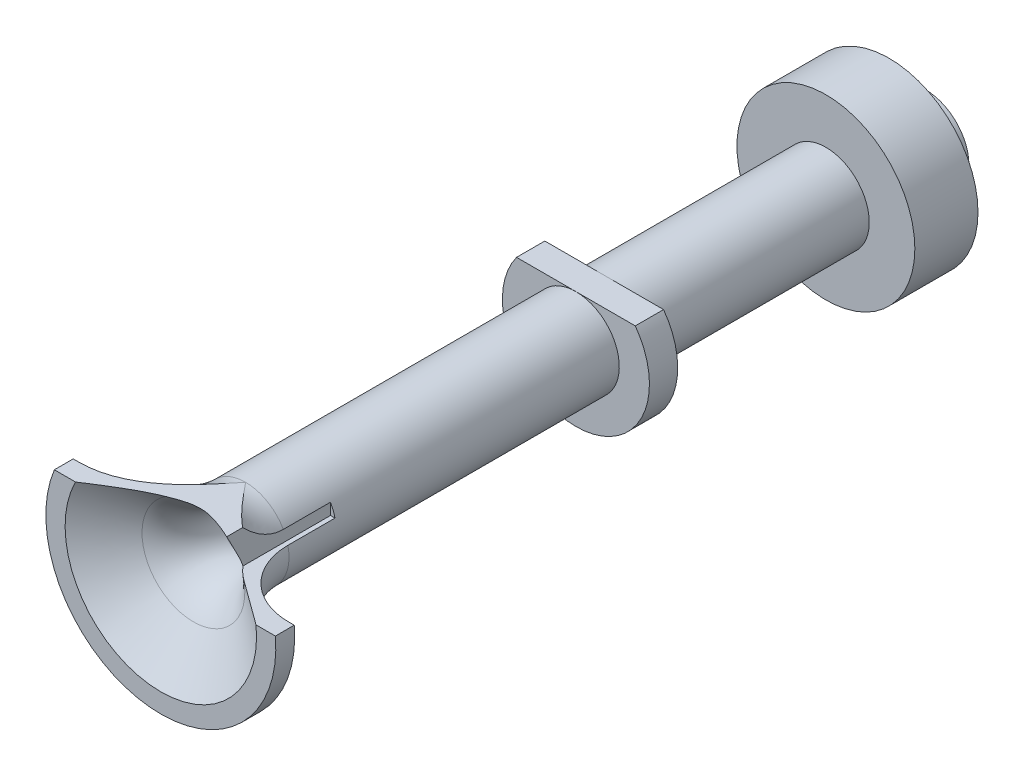
from build123d import *

# Parameters (mm, degrees)
CUT_EXTRUDE1_DEPTH      = 7
SKETCH3_W               = 26.933594661
SKETCH3_H               = 5.726695828
CUT_EXTRUDE2_DEPTH      = 7.1
CUT_EXTRUDE2_DEPTH_BACK = 7.1


with BuildPart() as part:
    # Sketch1 → Revolve1 (revolve)
    with BuildSketch(Plane(origin=(0, 0, 0), x_dir=(0, 0, -1), z_dir=(1, 0, 0))):
        with BuildLine():
            Line((19.186178752, 5.078211692), (19.186178752, 6.1))
            Line((19.186178752, 6.1), (20.186178752, 6.1))
            Line((20.186178752, 6.1), (20.186178752, 5.8))
            ThreePointArc((20.186178752, 5.8), (21.211305018, 3.325126266), (23.686178752, 2.3))
            Line((23.686178752, 2.3), (41.207308429, 2.3))
            Line((41.207308429, 2.3), (41.207308429, 3.9))
            Line((41.207308429, 3.9), (42.707308429, 3.9))
            Line((42.707308429, 3.9), (42.707308429, 2.3))
            Line((42.707308429, 2.3), (54.469152884, 2.3))
            Line((54.469152884, 2.3), (54.469152884, 4.719165839))
            Line((54.469152884, 4.719165839), (57.819152884, 4.719165839))
            Line((57.819152884, 4.719165839), (57.819152884, 2.3))
            Line((57.819152884, 2.3), (59.757795324, 2.3))
            Line((59.757795324, 2.3), (59.757795324, 1.3))
            Line((59.757795324, 1.3), (23.73491848, 1.3))
            ThreePointArc((23.73491848, 1.3), (22.154791951, 1.676988608), (20.915059537, 2.72674277))
            Line((20.915059537, 2.72674277), (19.186178752, 5.078211692))
        make_face()
    revolve(axis=Axis((0, 0, 0), (0, 0, -1)))

    # Sketch2 → Cut-Extrude1 (cut)
    with BuildSketch(Plane.XY.offset(-19.186178752)):
        Polygon((2, 6), (2, 0.524681536), (7.756224258, 0.524681536), (7.708002274, 5.9580813), align=None)
    extrude(amount=-CUT_EXTRUDE1_DEPTH, mode=Mode.SUBTRACT)

    # Sketch3 → Cut-Extrude2 (cut, two sides)
    with BuildSketch(Plane(origin=(0, 0, 0), x_dir=(0, 0, -1), z_dir=(1, 0, 0))) as cut_extrude2_sk:
        with Locations((31.133671125, 5.163347914)):
            Rectangle(SKETCH3_W, SKETCH3_H)
    extrude(amount=CUT_EXTRUDE2_DEPTH, mode=Mode.SUBTRACT)
    extrude(cut_extrude2_sk.sketch, amount=-CUT_EXTRUDE2_DEPTH_BACK, mode=Mode.SUBTRACT)


solid = part.part
